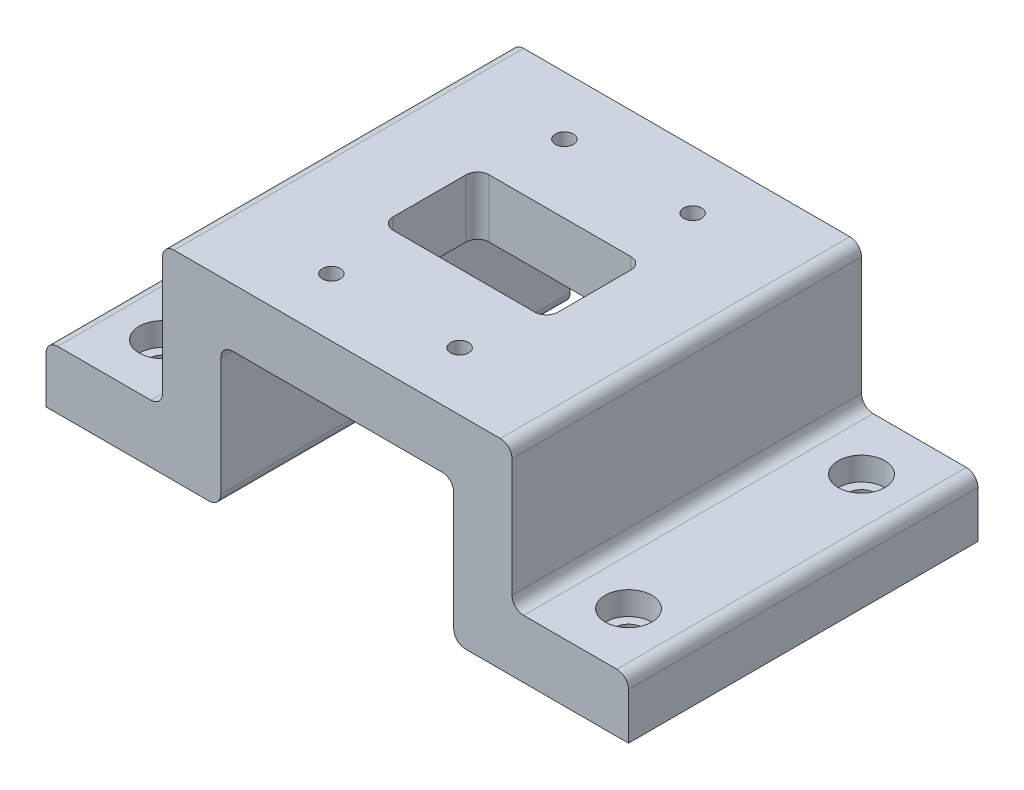
from build123d import *

# Parameters (mm, degrees)
SKETCH2_W                        = 60
SKETCH2_H                        = 60
BOSS_EXTRUDE1_DEPTH              = 10
SKETCH7_W                        = 28.32
SKETCH7_H                        = 16.5
CUT_EXTRUDE2_DEPTH               = 44.588989435
FILLET2_R                        = 2
CBORE_FOR_M2_5_SHCS2_D           = 3.1
CBORE_FOR_M2_5_SHCS2_CBORE_D     = 5.5
CBORE_FOR_M2_5_SHCS2_CBORE_DEPTH = 2.5
MOVE_FACE1_BY                    = 3.5
MOVE_FACE1_2_BY                  = 3.5
MOVE_FACE1_3_BY                  = 3.5
MOVE_FACE1_4_BY                  = 3.5
SKETCH11_W                       = 10
SKETCH11_H                       = 24.3
BOSS_EXTRUDE2_DEPTH              = 60
SKETCH12_W                       = 20
SKETCH12_H                       = 60
BOSS_EXTRUDE3_DEPTH              = 10
CBORE_FOR_M4_SHCS1_D             = 4.8
CBORE_FOR_M4_SHCS1_CBORE_D       = 8
CBORE_FOR_M4_SHCS1_CBORE_DEPTH   = 4
FILLET5_R                        = 2


with BuildPart() as part:
    # Sketch2 → Boss-Extrude1 (new body)
    with BuildSketch(Plane(origin=(0, 0, 0), x_dir=(1, 0, 0), z_dir=(0, 1, 0))):
        Rectangle(SKETCH2_W, SKETCH2_H)
    extrude(amount=BOSS_EXTRUDE1_DEPTH)

    # Sketch7 → Cut-Extrude2 (cut, through all)
    with BuildSketch(Plane(origin=(0, 10, 0), x_dir=(1, 0, 0), z_dir=(0, 1, 0))):
        Rectangle(SKETCH7_W, SKETCH7_H)
    extrude(amount=-CUT_EXTRUDE2_DEPTH, mode=Mode.SUBTRACT)

    # Fillet2
    fillet2_edges = [part.edges().sort_by_distance(p)[0] for p in [
        (-14.16, 5, 8.25),
        (-14.16, 5, -8.25),
        (14.16, 5, -8.25),
        (14.16, 5, 8.25),
    ]]
    fillet(fillet2_edges, radius=FILLET2_R)

    # CBORE for M2.5 SHCS2 (through all)
    with Locations(Plane(origin=(0, 0, 0), x_dir=(-1, 0, 0), z_dir=(0, -1, 0))):
        with Locations((11, -20), (-11, -20), (11, 20), (-11, 20)):
            CounterBoreHole(CBORE_FOR_M2_5_SHCS2_D / 2, CBORE_FOR_M2_5_SHCS2_CBORE_D / 2, CBORE_FOR_M2_5_SHCS2_CBORE_DEPTH)

    # Move Face1: a face moved inward by 3.5
    extrude(part.faces().sort_by_distance((11, 2.5, 22.2))[0], amount=MOVE_FACE1_BY, dir=(0, 1, 0), mode=Mode.SUBTRACT)

    # Move Face1 2: a face moved inward by 3.5
    extrude(part.faces().sort_by_distance((-11, 2.5, 22.2))[0], amount=MOVE_FACE1_2_BY, dir=(0, 1, 0), mode=Mode.SUBTRACT)

    # Move Face1 3: a face moved inward by 3.5
    extrude(part.faces().sort_by_distance((11, 2.5, -17.8))[0], amount=MOVE_FACE1_3_BY, dir=(0, 1, 0), mode=Mode.SUBTRACT)

    # Move Face1 4: a face moved inward by 3.5
    extrude(part.faces().sort_by_distance((-11, 2.5, -17.8))[0], amount=MOVE_FACE1_4_BY, dir=(0, 1, 0), mode=Mode.SUBTRACT)

    # Sketch11 → Boss-Extrude2 (add)
    with BuildSketch(Plane(origin=(0, 0, -30), x_dir=(-1, 0, 0), z_dir=(0, 0, -1))):
        with Locations((-25, -12.15)):
            Rectangle(SKETCH11_W, SKETCH11_H)
    boss_extrude2 = extrude(amount=-BOSS_EXTRUDE2_DEPTH)

    # Sketch12 → Boss-Extrude3 (add)
    with BuildSketch(Plane.XZ.offset(24.3)):
        with Locations((40, 0)):
            Rectangle(SKETCH12_W, SKETCH12_H)
    boss_extrude3 = extrude(amount=-BOSS_EXTRUDE3_DEPTH)

    # CBORE for M4 SHCS1 (through all)
    with Locations(Plane(origin=(0, -14.3, 0), x_dir=(1, 0, 0), z_dir=(0, 1, 0))):
        with Locations((40, 20), (40, -20)):
            cbore_for_m4_shcs1 = CounterBoreHole(CBORE_FOR_M4_SHCS1_D / 2, CBORE_FOR_M4_SHCS1_CBORE_D / 2, CBORE_FOR_M4_SHCS1_CBORE_DEPTH)

    # Mirror1: Boss-Extrude2, Boss-Extrude3, CBORE for M4 SHCS1 across plane
    add(boss_extrude2.mirror(Plane(origin=(0, 0, 0), x_dir=(0, 0, 1), z_dir=(1, 0, 0))))
    add(boss_extrude3.mirror(Plane(origin=(0, 0, 0), x_dir=(0, 0, 1), z_dir=(1, 0, 0))))
    add(cbore_for_m4_shcs1.mirror(Plane(origin=(0, 0, 0), x_dir=(0, 0, 1), z_dir=(1, 0, 0))), mode=Mode.SUBTRACT)

    # Fillet5
    fillet5_edges = [part.edges().sort_by_distance(p)[0] for p in [
        (50, -14.3, 0),
        (30, -14.3, 0),
        (30, 10, 0),
        (-20, 0, 0),
        (-20, -24.3, 0),
        (-30, -14.3, 0),
        (-50, -14.3, 0),
        (-30, 10, 0),
        (20, 0, 0),
        (20, -24.3, 0),
    ]]
    fillet(fillet5_edges, radius=FILLET5_R)


solid = part.part
